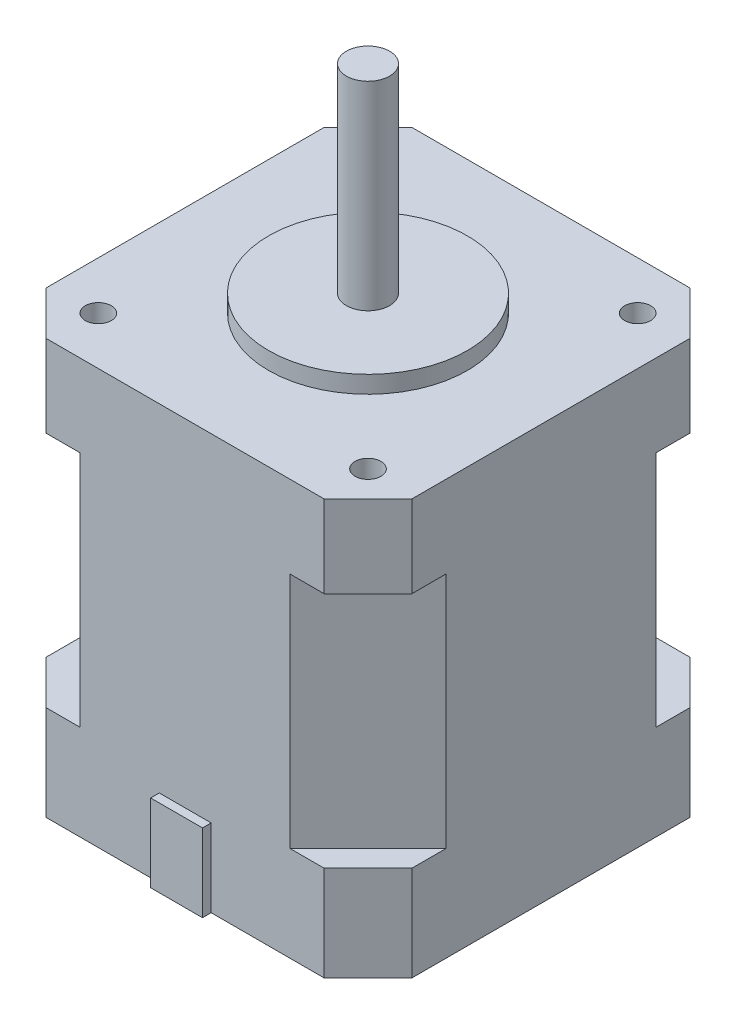
from build123d import *

# Parameters (mm, degrees)
SKETCH1_W               = 42.3
SKETCH1_H               = 42.3
BOSS_EXTRUDE1_DEPTH     = 48
SKETCH2_R               = 11.5
BOSS_EXTRUDE2_DEPTH     = 2
SKETCH3_R               = 2.5
BOSS_EXTRUDE3_DEPTH     = 23
SKETCH4_R               = 1.5
CUT_EXTRUDE1_DEPTH      = 8
MIRROR3_COPY_1_SKETCH_R = 1.5
MIRROR3_COPY_1_DEPTH    = 8
CUT_EXTRUDE2_DEPTH      = 9.5
MIRROR5_COPY_1_DEPTH    = 9.5
SKETCH7_R               = 2.5
CUT_EXTRUDE5_DEPTH      = 5
CUT_EXTRUDE6_DEPTH      = 11
MIRROR7_COPY_1_DEPTH    = 11
CUT_EXTRUDE7_DEPTH      = 27.5
CUT_EXTRUDE8_DEPTH      = 27.5
CUT_EXTRUDE9_DEPTH      = 27.5
CUT_EXTRUDE10_DEPTH     = 27.5
BOSS_EXTRUDE4_DEPTH     = 1


with BuildPart() as part:
    # Sketch1 → Boss-Extrude1 (new body)
    with BuildSketch(Plane(origin=(0, 0, 0), x_dir=(1, 0, 0), z_dir=(0, 1, 0))):
        Rectangle(SKETCH1_W, SKETCH1_H)
    extrude(amount=BOSS_EXTRUDE1_DEPTH)

    # Sketch2 → Boss-Extrude2 (add)
    with BuildSketch(Plane(origin=(0, 48, 0), x_dir=(1, 0, 0), z_dir=(0, 1, 0))):
        Circle(SKETCH2_R)
    extrude(amount=BOSS_EXTRUDE2_DEPTH)

    # Sketch3 → Boss-Extrude3 (add)
    with BuildSketch(Plane(origin=(0, 50, 0), x_dir=(1, 0, 0), z_dir=(0, 1, 0))):
        Circle(SKETCH3_R)
    extrude(amount=BOSS_EXTRUDE3_DEPTH)

    # Sketch4 → Cut-Extrude1 (cut)
    with BuildSketch(Plane(origin=(0, 48, 0), x_dir=(1, 0, 0), z_dir=(0, 1, 0))):
        with Locations((-15.6, 15.6)):
            Circle(SKETCH4_R)
    cut_extrude1 = extrude(amount=-CUT_EXTRUDE1_DEPTH, mode=Mode.SUBTRACT)

    # Mirror1: Cut-Extrude1 across plane
    add(cut_extrude1.mirror(Plane(origin=(0, 0, 0), x_dir=(0, 0, 1), z_dir=(1, 0, 0))), mode=Mode.SUBTRACT)

    # Mirror3: Cut-Extrude1 across plane
    add(cut_extrude1.mirror(Plane.XY), mode=Mode.SUBTRACT)

    # Mirror3 copy 1 sketch → Mirror3 copy 1 (cut)
    with BuildSketch(Plane(origin=(0, 48, 0), x_dir=(-1, 0, 0), z_dir=(0, 1, 0))):
        with Locations((-15.6, 15.6)):
            Circle(MIRROR3_COPY_1_SKETCH_R)
    extrude(amount=-MIRROR3_COPY_1_DEPTH, mode=Mode.SUBTRACT)

    # Sketch6 → Cut-Extrude2 (cut)
    with BuildSketch(Plane(origin=(0, 48, 0), x_dir=(1, 0, 0), z_dir=(0, 1, 0))):
        Polygon((-21.15, 21.15), (-21.15, 16.08), (-16.08, 21.15), align=None)
    cut_extrude2 = extrude(amount=-CUT_EXTRUDE2_DEPTH, mode=Mode.SUBTRACT)

    # Mirror4: Cut-Extrude2 across plane
    add(cut_extrude2.mirror(Plane(origin=(0, 0, 0), x_dir=(0, 0, 1), z_dir=(1, 0, 0))), mode=Mode.SUBTRACT)

    # Mirror5: Cut-Extrude2 across plane
    add(cut_extrude2.mirror(Plane.XY), mode=Mode.SUBTRACT)

    # Mirror5 copy 1 sketch → Mirror5 copy 1 (cut)
    with BuildSketch(Plane(origin=(0, 48, 0), x_dir=(-1, 0, 0), z_dir=(0, 1, 0))):
        Polygon((-21.15, 21.15), (-21.15, 16.08), (-16.08, 21.15), align=None)
    extrude(amount=-MIRROR5_COPY_1_DEPTH, mode=Mode.SUBTRACT)

    # Sketch7 → Cut-Extrude5 (cut)
    with BuildSketch(Plane.XZ):
        Circle(SKETCH7_R)
    extrude(amount=-CUT_EXTRUDE5_DEPTH, mode=Mode.SUBTRACT)

    # Sketch8 → Cut-Extrude6 (cut)
    with BuildSketch(Plane.XZ):
        Polygon((-21.15, 21.15), (-21.15, 16.08), (-16.08, 21.15), align=None)
    cut_extrude6 = extrude(amount=-CUT_EXTRUDE6_DEPTH, mode=Mode.SUBTRACT)

    # Mirror6: Cut-Extrude6 across plane
    add(cut_extrude6.mirror(Plane(origin=(0, 0, 0), x_dir=(0, 0, 1), z_dir=(1, 0, 0))), mode=Mode.SUBTRACT)

    # Mirror7: Cut-Extrude6 across plane
    add(cut_extrude6.mirror(Plane.XY), mode=Mode.SUBTRACT)

    # Mirror7 copy 1 sketch → Mirror7 copy 1 (cut)
    with BuildSketch(Plane(origin=(0, 0, 0), x_dir=(-1, 0, 0), z_dir=(0, -1, 0))):
        Polygon((-21.15, 21.15), (-21.15, 16.08), (-16.08, 21.15), align=None)
    extrude(amount=-MIRROR7_COPY_1_DEPTH, mode=Mode.SUBTRACT)

    # Sketch10 → Cut-Extrude7 (cut)
    with BuildSketch(Plane(origin=(0, 38.5, 0), x_dir=(1, 0, 0), z_dir=(0, 1, 0))):
        Polygon((-21.15, 21.15), (-12.15, 21.15), (-21.15, 12.15), align=None)
    extrude(amount=-CUT_EXTRUDE7_DEPTH, mode=Mode.SUBTRACT)

    # Sketch11 → Cut-Extrude8 (cut)
    with BuildSketch(Plane(origin=(0, 38.5, 0), x_dir=(1, 0, 0), z_dir=(0, 1, 0))):
        Polygon((21.15, 21.15), (12.15, 21.15), (21.15, 12.15), align=None)
    extrude(amount=-CUT_EXTRUDE8_DEPTH, mode=Mode.SUBTRACT)

    # Sketch12 → Cut-Extrude9 (cut)
    with BuildSketch(Plane(origin=(0, 38.5, 0), x_dir=(1, 0, 0), z_dir=(0, 1, 0))):
        Polygon((-21.15, -21.15), (-12.15, -21.15), (-21.15, -12.15), align=None)
    extrude(amount=-CUT_EXTRUDE9_DEPTH, mode=Mode.SUBTRACT)

    # Sketch13 → Cut-Extrude10 (cut)
    with BuildSketch(Plane(origin=(0, 38.5, 0), x_dir=(1, 0, 0), z_dir=(0, 1, 0))):
        Polygon((21.15, -21.15), (21.15, -12.15), (12.15, -21.15), align=None)
    extrude(amount=-CUT_EXTRUDE10_DEPTH, mode=Mode.SUBTRACT)

    # Sketch14 → Boss-Extrude4 (add)
    with BuildSketch(Plane.XY.offset(21.15)):
        Polygon((0, 0), (-3, 0), (-3, 9), (3, 9), (3, 0), align=None)
    extrude(amount=BOSS_EXTRUDE4_DEPTH)


solid = part.part
